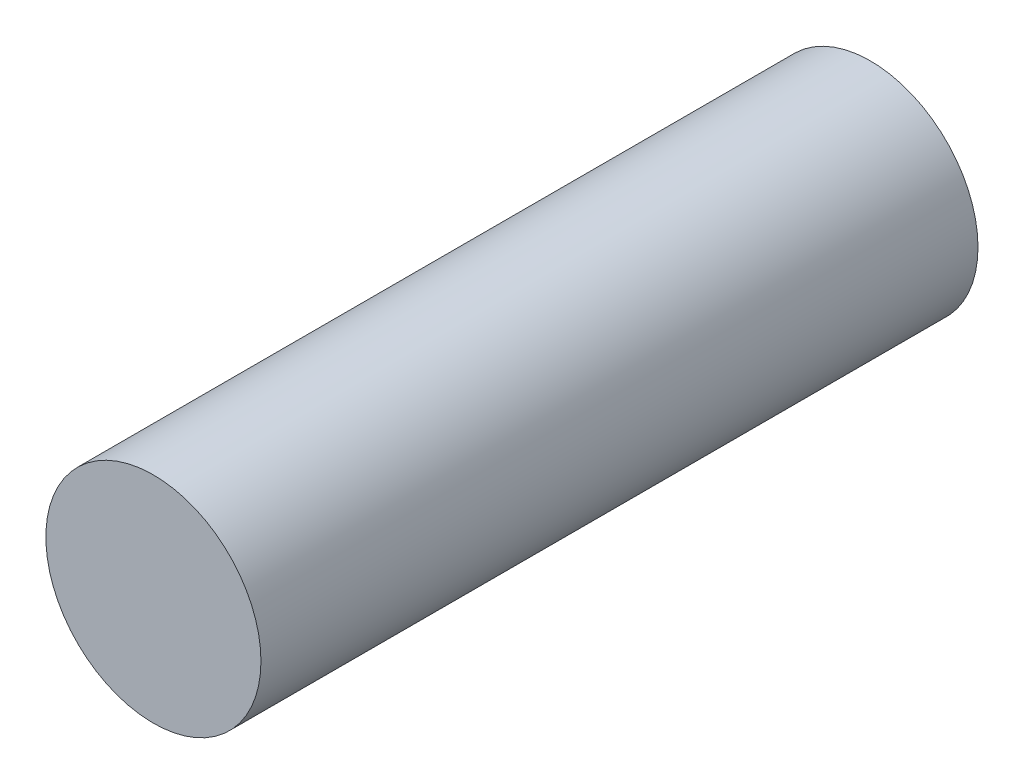
from build123d import *

# Parameters (mm, degrees)
ESQUISSE1_R        = 42
BOSS_EXTRU_1_DEPTH = 280


with BuildPart() as part:
    # Esquisse1 → Boss.-Extru.1 (new body)
    with BuildSketch(Plane.XY):
        Circle(ESQUISSE1_R)
    extrude(amount=BOSS_EXTRU_1_DEPTH)


solid = part.part
